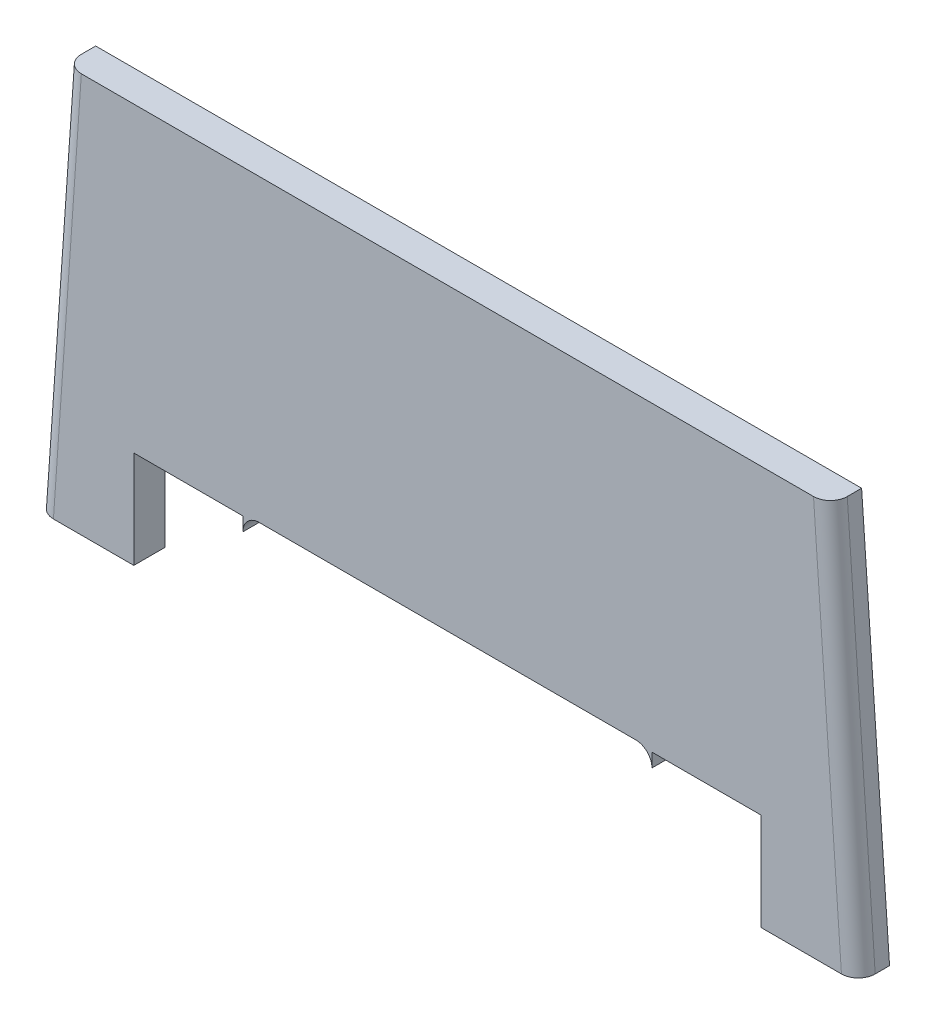
from build123d import *

# Parameters (mm, degrees)
BOSS_EXTRUDE1_DEPTH = 25
FILLET1_R           = 13.5


with BuildPart() as part:
    # Sketch1 → Boss-Extrude1 (new body)
    with BuildSketch(Plane.XY):
        with BuildLine():
            Line((-251.2, -2), (-251.2, -80))
            Line((-251.2, -80), (-329.1, -80))
            Line((-329.1, -80), (-306.723420178, 240))
            Line((-306.723420178, 240), (306.723420178, 240))
            Line((306.723420178, 240), (329.1, -80))
            Line((329.1, -80), (251.2, -80))
            Line((251.2, -80), (251.2, -2))
            Line((251.2, -2), (163.8, -2))
            Line((163.8, -2), (163.8, -13))
            ThreePointArc((163.8, -13), (159.992388155, -3.807611845), (150.8, 0))
            Line((150.8, 0), (-150.8, 0))
            ThreePointArc((-150.8, 0), (-159.992388155, -3.807611845), (-163.8, -13))
            Line((-163.8, -13), (-163.8, -2))
            Line((-163.8, -2), (-251.2, -2))
        make_face()
    extrude(amount=BOSS_EXTRUDE1_DEPTH)

    # Fillet1
    fillet1_edges = [part.edges().sort_by_distance(p)[0] for p in [
        (317.911710089, 80, 25),
        (-317.911710089, 80, 25),
    ]]
    fillet(fillet1_edges, radius=FILLET1_R)


solid = part.part
